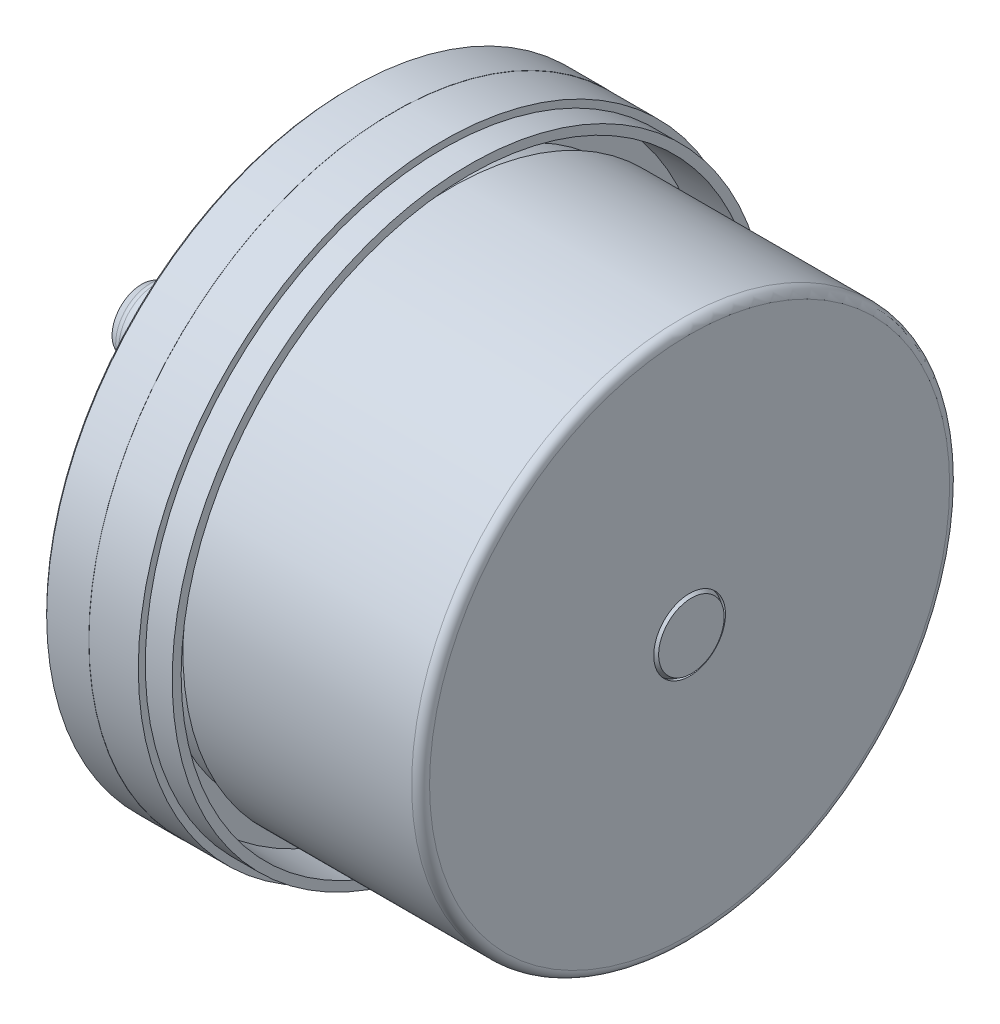
from build123d import *

# Parameters (mm, degrees)
F_3_3_3_3_DIAMETER_HOLE1_D     = 3.3
F_3_3_3_3_DIAMETER_HOLE1_DEPTH = 7.3
F_3_3_3_3_DIAMETER_HOLE1_TIP   = 0.991420021
CHAMFER1_SIZE                  = 0.55
CHAMFER2_SIZE                  = 0.3
FILLET1_R                      = 0.5
FILLET2_R                      = 1


with BuildPart() as part:
    # Sketch1 → Revolve1 (revolve)
    with BuildSketch(Plane.XY):
        with BuildLine():
            Line((-23.1, 3.307179677), (-23.1, 0))
            Line((-23.1, 0), (38.2, 0))
            Line((38.2, 0), (38.2, 3.653589838))
            Line((38.2, 3.653589838), (37.6, 4))
            Line((37.6, 4), (38, 4))
            Line((38, 4), (38, 30))
            Line((38, 30), (11.5, 30))
            Line((11.5, 30), (11.5, 29))
            Line((11.5, 29), (7.8, 29))
            Line((7.8, 29), (7.8, 32.000951614))
            Line((7.8, 32.000951614), (13.5, 32.2))
            Line((13.5, 32.2), (13.5, 33.2))
            Line((13.5, 33.2), (10.5, 33.2))
            Line((10.5, 33.2), (10.5, 33.98))
            Line((10.5, 33.98), (5, 33.98))
            Line((5, 33.98), (5, 34))
            Line((5, 34), (0, 34))
            Line((0, 34), (0, 11.288675135))
            Line((0, 11.288675135), (0.5, 11))
            Line((0.5, 11), (-2.6, 11))
            Line((-2.6, 11), (-2.6, 4.5))
            ThreePointArc((-2.6, 4.5), (-2.453553391, 4.146446609), (-2.1, 4))
            Line((-2.1, 4), (-21.9, 4))
            Line((-21.9, 4), (-23.1, 3.307179677))
        make_face()
    revolve(axis=Axis((-23.1, 0, 0), (1, 0, 0)))

    # Ø3.3 (3.3) Diameter Hole1
    with Locations(Plane.ZY):
        with Locations((0, 21.5), (18.619546181, -10.75), (-18.619546181, -10.75)):
            Hole(F_3_3_3_3_DIAMETER_HOLE1_D / 2, depth=F_3_3_3_3_DIAMETER_HOLE1_DEPTH)
            with Locations((0, 0, -(F_3_3_3_3_DIAMETER_HOLE1_DEPTH + F_3_3_3_3_DIAMETER_HOLE1_TIP / 2))):  # 118° drill point
                Cone(0, F_3_3_3_3_DIAMETER_HOLE1_D / 2, F_3_3_3_3_DIAMETER_HOLE1_TIP, mode=Mode.SUBTRACT)

    # Chamfer1
    chamfer1_edges = [part.edges().sort_by_distance(p)[0] for p in [
        (0, 21.5, 1.65),
        (0, -10.75, 20.269546181),
        (0, -10.75, -16.969546181),
    ]]
    chamfer(chamfer1_edges, length=CHAMFER1_SIZE)

    # Chamfer2
    chamfer2_edges = [part.edges().sort_by_distance(p)[0] for p in [
        (0, -34, 0),
    ]]
    chamfer(chamfer2_edges, length=CHAMFER2_SIZE)

    # Fillet1
    fillet1_edges = [part.edges().sort_by_distance(p)[0] for p in [
        (-2.6, -11, 0),
    ]]
    fillet(fillet1_edges, radius=FILLET1_R)

    # Fillet2
    fillet2_edges = [part.edges().sort_by_distance(p)[0] for p in [
        (38, -30, 0),
        (-21.9, -4, 0),
    ]]
    fillet(fillet2_edges, radius=FILLET2_R)


solid = part.part
